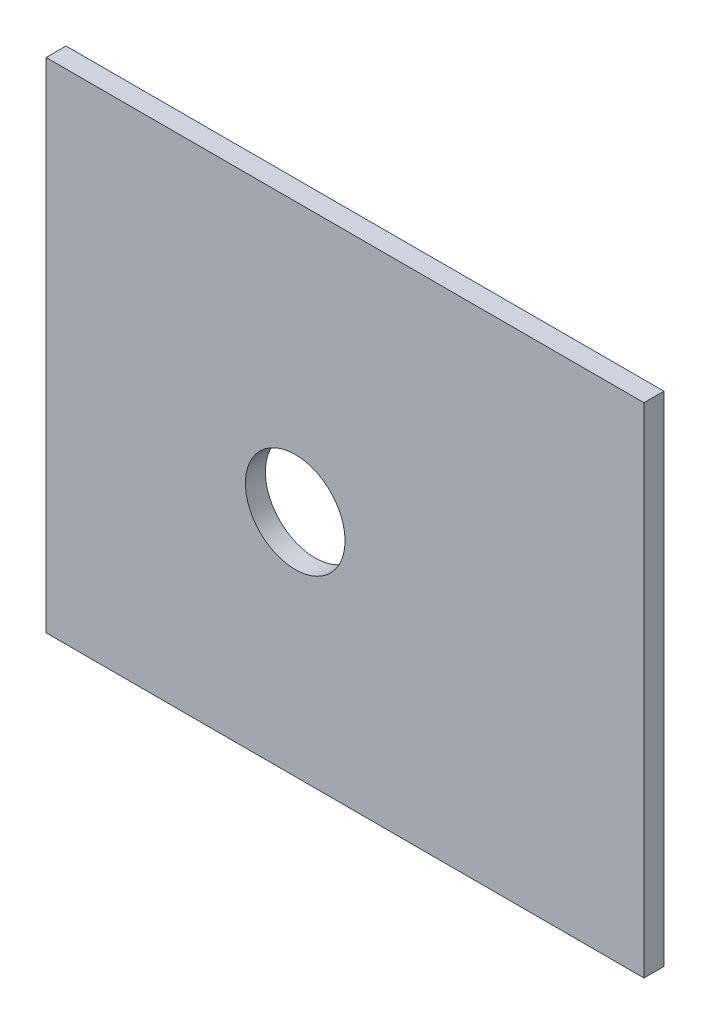
from build123d import *

# Parameters (mm, degrees)
SKETCH1_W           = 60
SKETCH1_H           = 50
SKETCH1_R           = 5
BOSS_EXTRUDE1_DEPTH = 2


with BuildPart() as part:
    # Sketch1 → Boss-Extrude1 (new body)
    with BuildSketch(Plane.XY):
        Rectangle(SKETCH1_W, SKETCH1_H)
        with Locations((-5, -2)):
            Circle(SKETCH1_R, mode=Mode.SUBTRACT)
    extrude(amount=BOSS_EXTRUDE1_DEPTH)


solid = part.part
